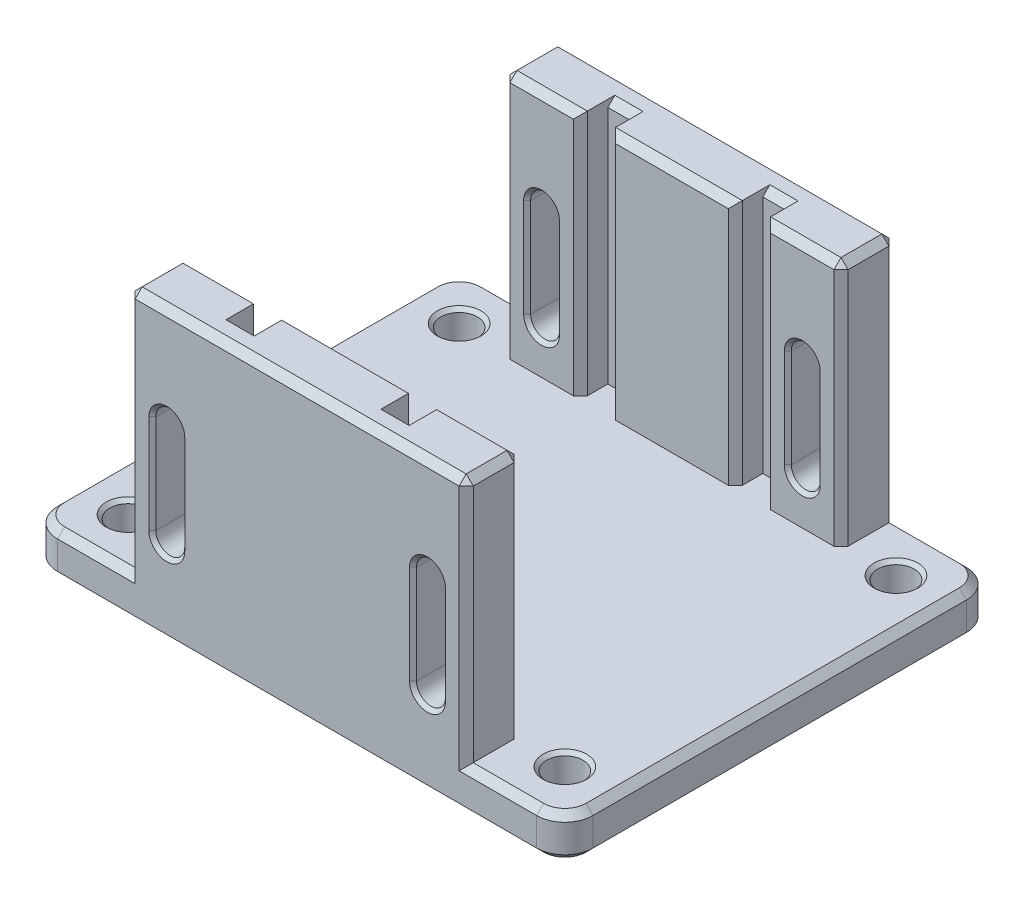
from build123d import *

# Parameters (mm, degrees)
BOSS_EXTRUDE1_DEPTH     = 24
SKETCH3_W               = 4
SKETCH3_H               = 35
CUT_EXTRUDE1_DEPTH      = 26.6
CUT_EXTRUDE2_DEPTH      = 31.5
CUT_EXTRUDE2_DEPTH_BACK = 31.5
SKETCH5_W               = 14
SKETCH5_H               = 61
SKETCH5_R               = 2.6
BOSS_EXTRUDE2_DEPTH     = 6
FILLET1_R               = 4
CHAMFER1_SIZE           = 1
CHAMFER2_SIZE           = 0.5


with BuildPart() as part:
    # Sketch2 → Boss-Extrude1 (new body, symmetric)
    with BuildSketch(Plane(origin=(0, 0, 0), x_dir=(0, 0, -1), z_dir=(1, 0, 0))):
        Polygon((-30.5, 35), (-22.7, 35), (-22.7, 0), (0, 0), (22.7, 0), (22.7, 35), (30.5, 35), (30.5, -6), (-30.5, -6), align=None)
    extrude(amount=BOSS_EXTRUDE1_DEPTH, both=True)

    # Sketch3 → Cut-Extrude1 (cut, symmetric)
    with BuildSketch(Plane.XY):
        with Locations((-11, 17.5)):
            Rectangle(SKETCH3_W, SKETCH3_H)
        with Locations((11, 17.5)):
            Rectangle(SKETCH3_W, SKETCH3_H)
    extrude(amount=CUT_EXTRUDE1_DEPTH, both=True, mode=Mode.SUBTRACT)

    # Sketch4 → Cut-Extrude2 (cut, two sides)
    with BuildSketch(Plane.XY) as cut_extrude2_sk:
        with BuildLine():
            Line((-16.45, 20.5), (-16.45, 6.5))
            ThreePointArc((-16.45, 6.5), (-18.5, 4.45), (-20.55, 6.5))
            Line((-20.55, 6.5), (-20.55, 20.5))
            ThreePointArc((-20.55, 20.5), (-18.5, 22.55), (-16.45, 20.5))
        make_face()
        with BuildLine():
            Line((20.55, 20.5), (20.55, 6.5))
            ThreePointArc((20.55, 6.5), (18.5, 4.45), (16.45, 6.5))
            Line((16.45, 6.5), (16.45, 20.5))
            ThreePointArc((16.45, 20.5), (18.5, 22.55), (20.55, 20.5))
        make_face()
    extrude(amount=CUT_EXTRUDE2_DEPTH, mode=Mode.SUBTRACT)
    extrude(cut_extrude2_sk.sketch, amount=-CUT_EXTRUDE2_DEPTH_BACK, mode=Mode.SUBTRACT)

    # Sketch5 → Boss-Extrude2 (add)
    with BuildSketch(Plane(origin=(0, 0, 0), x_dir=(1, 0, 0), z_dir=(0, 1, 0))):
        with Locations((-31, 0)):
            Rectangle(SKETCH5_W, SKETCH5_H)
        with Locations((-31, 23.5)):
            Circle(SKETCH5_R, mode=Mode.SUBTRACT)
        with Locations((-31, -23.5)):
            Circle(SKETCH5_R, mode=Mode.SUBTRACT)
        with Locations((31, 0)):
            Rectangle(SKETCH5_W, SKETCH5_H)
        with Locations((31, 23.5)):
            Circle(SKETCH5_R, mode=Mode.SUBTRACT)
        with Locations((31, -23.5)):
            Circle(SKETCH5_R, mode=Mode.SUBTRACT)
    extrude(amount=-BOSS_EXTRUDE2_DEPTH)

    # Fillet1
    fillet1_edges = [part.edges().sort_by_distance(p)[0] for p in [
        (-38, -3, -30.5),
        (-38, -3, 30.5),
        (38, -3, 30.5),
        (38, -3, -30.5),
    ]]
    fillet(fillet1_edges, radius=FILLET1_R)

    # Chamfer1
    chamfer1_edges = [part.edges().sort_by_distance(p)[0] for p in [
        (-24, 17.5, -22.7),
        (-24, 35, -26.6),
        (-24, 17.5, 30.5),
        (24, 35, -26.6),
        (-24, 17.5, -30.5),
        (-29, 0, -30.5),
        (0, 35, 30.5),
        (18.5, 35, 22.7),
        (24, 17.5, -30.5),
        (18.5, 35, -22.7),
        (29, 0, 30.5),
        (0, 35, -30.5),
        (24, 17.5, -22.7),
        (0, -6, -30.5),
        (29, 0, -30.5),
        (-38, 0, 0),
        (-29, 0, 30.5),
        (38, 0, 0),
        (36.828427125, 0, 29.328427125),
        (36.828427125, 0, -29.328427125),
        (-36.828427125, 0, 29.328427125),
        (-36.828427125, 0, -29.328427125),
        (-38, -6, 0),
        (0, -6, 30.5),
        (38, -6, 0),
        (36.828427125, -6, 29.328427125),
        (36.828427125, -6, -29.328427125),
        (-36.828427125, -6, 29.328427125),
        (-36.828427125, -6, -29.328427125),
        (24, 17.5, 22.7),
        (0, 35, 22.7),
        (24, 35, 26.6),
        (-18.5, 35, 22.7),
        (0, 35, -22.7),
        (-18.5, 35, -22.7),
        (24, 17.5, 30.5),
        (-11, 35, -26.6),
        (-13, 17.5, -22.7),
        (-13, 17.5, 22.7),
        (-9, 17.5, -22.7),
        (-9, 17.5, 22.7),
        (-11, 35, 26.6),
        (11, 35, -26.6),
        (9, 17.5, -22.7),
        (9, 17.5, 22.7),
        (13, 17.5, -22.7),
        (13, 17.5, 22.7),
        (11, 35, 26.6),
        (-24, 35, 26.6),
        (-24, 17.5, 22.7),
    ]]
    chamfer(chamfer1_edges, length=CHAMFER1_SIZE)

    # Chamfer2
    chamfer2_edges = [part.edges().sort_by_distance(p)[0] for p in [
        (-18.5, 22.55, 30.5),
        (-20.55, 13.5, 30.5),
        (-18.5, 4.45, 30.5),
        (-16.45, 13.5, 30.5),
        (18.5, 22.55, -22.7),
        (18.5, 22.55, -30.5),
        (20.55, 13.5, -22.7),
        (20.55, 13.5, -30.5),
        (18.5, 4.45, -22.7),
        (18.5, 4.45, -30.5),
        (16.45, 13.5, -22.7),
        (16.45, 13.5, -30.5),
        (18.5, 22.55, 30.5),
        (16.45, 13.5, 30.5),
        (18.5, 4.45, 30.5),
        (20.55, 13.5, 30.5),
        (-33.6, -6, -23.5),
        (-33.6, 0, -23.5),
        (-33.6, -6, 23.5),
        (-33.6, 0, 23.5),
        (28.4, -6, -23.5),
        (28.4, 0, -23.5),
        (28.4, -6, 23.5),
        (28.4, 0, 23.5),
        (16.45, 13.5, 22.7),
        (18.5, 4.45, 22.7),
        (20.55, 13.5, 22.7),
        (18.5, 22.55, 22.7),
        (-18.5, 22.55, -22.7),
        (-18.5, 22.55, -30.5),
        (-18.5, 22.55, 22.7),
        (-16.45, 13.5, -22.7),
        (-16.45, 13.5, -30.5),
        (-16.45, 13.5, 22.7),
        (-18.5, 4.45, -22.7),
        (-18.5, 4.45, -30.5),
        (-18.5, 4.45, 22.7),
        (-20.55, 13.5, -22.7),
        (-20.55, 13.5, -30.5),
        (-20.55, 13.5, 22.7),
    ]]
    chamfer(chamfer2_edges, length=CHAMFER2_SIZE)


solid = part.part
